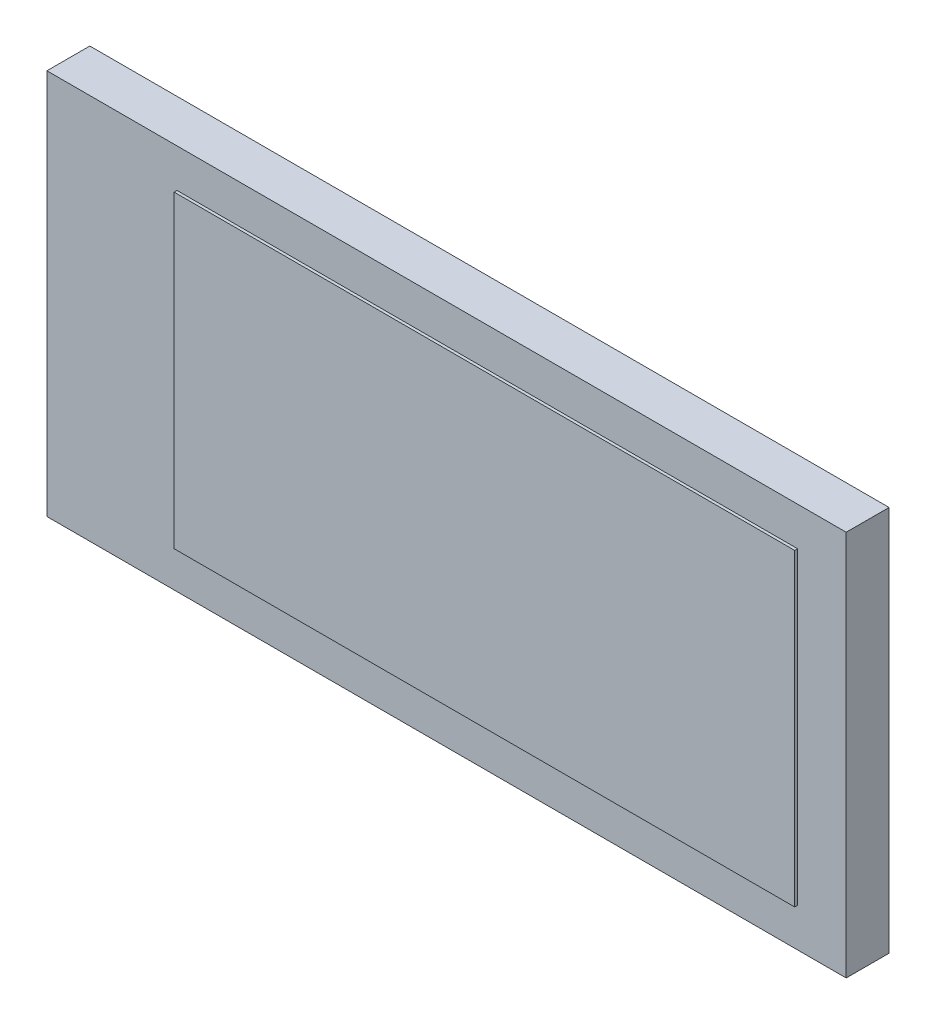
from build123d import *

# Parameters (mm, degrees)
SKETCH_1_W      = 27.95
SKETCH_1_H      = 13.5
EXTRUDE_1_DEPTH = 1.5
SKETCH_2_W      = 21.7
SKETCH_2_H      = 10.8
EXTRUDE_2_DEPTH = 0.1


with BuildPart() as part:
    # 草图1 → 凸台-拉伸1 (new body)
    with BuildSketch(Plane.XY):
        with Locations((13.975, -6.75)):
            Rectangle(SKETCH_1_W, SKETCH_1_H)
    extrude(amount=EXTRUDE_1_DEPTH)

    # 草图2 → 凸台-拉伸2 (add)
    with BuildSketch(Plane.XY.offset(1.5)):
        with Locations((15.4, -6.75)):
            Rectangle(SKETCH_2_W, SKETCH_2_H)
    extrude(amount=EXTRUDE_2_DEPTH)


solid = part.part
